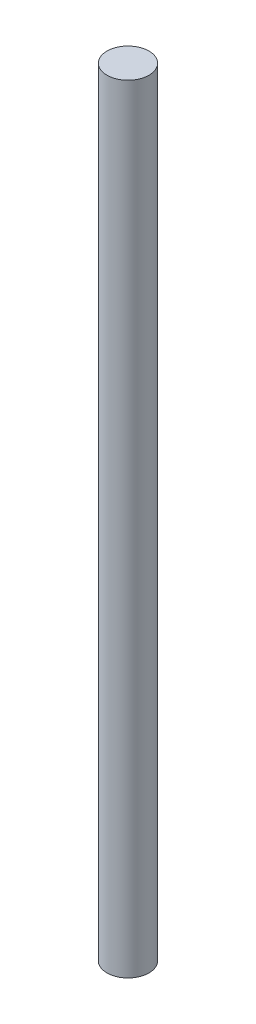
from build123d import *

# Parameters (mm, degrees)
CROQUIS1_R              = 4
SALIENTE_EXTRUIR1_DEPTH = 148.26


with BuildPart() as part:
    # Croquis1 → Saliente-Extruir1 (new body)
    with BuildSketch(Plane(origin=(0, 0, 0), x_dir=(1, 0, 0), z_dir=(0, 1, 0))):
        Circle(CROQUIS1_R)
    extrude(amount=SALIENTE_EXTRUIR1_DEPTH)


solid = part.part
